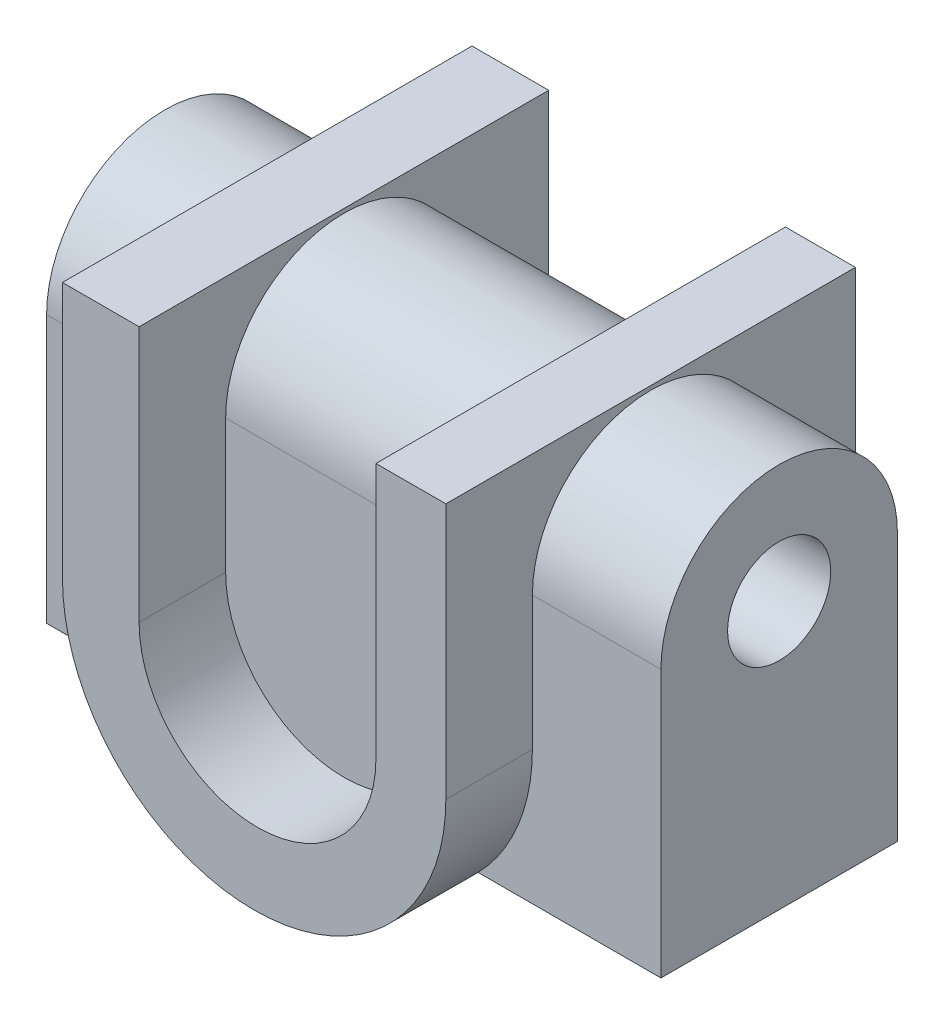
from build123d import *

# Parameters (mm, degrees)
BOSS_EXTRUDE1_DEPTH      = 40
SKETCH2_R                = 10.076891008
BOSS_EXTRUDE2_DEPTH      = 20
BOSS_EXTRUDE2_DEPTH_BACK = 100
SKETCH5_R                = 10.076891008
CUT_EXTRUDE1_DEPTH       = 101


with BuildPart() as part:
    # Sketch1 → Boss-Extrude1 (new body, symmetric)
    with BuildSketch(Plane.XY):
        with BuildLine():
            Line((0, 50.000244442), (0, 0))
            ThreePointArc((0, 0), (23.127866372, -23.127866372), (46.255732744, 0))
            Line((46.255732744, 0), (46.255732744, 50.000244442))
            Line((46.255732744, 50.000244442), (59.912187173, 50.000244442))
            Line((59.912187173, 50.000244442), (59.912187173, 0))
            ThreePointArc((59.912187173, 0), (22.46707019, -37.445116983), (-14.978046793, 0))
            Line((-14.978046793, 0), (-14.978046793, 50.000244442))
            Line((-14.978046793, 50.000244442), (0, 50.000244442))
        make_face()
    extrude(amount=BOSS_EXTRUDE1_DEPTH, both=True)

    # Sketch2 → Boss-Extrude2 (add, two sides)
    with BuildSketch(Plane.ZY.offset(14.978046793)) as boss_extrude2_sk:
        with BuildLine():
            Line((-23.095980377, -26.1078298), (23.095980377, -26.1078298))
            Line((23.095980377, -26.1078298), (23.095980377, 26.1078298))
            ThreePointArc((23.095980377, 26.1078298), (0, 49.203810178), (-23.095980377, 26.1078298))
            Line((-23.095980377, 26.1078298), (-23.095980377, -26.1078298))
        make_face()
        with Locations((0, 26.1078298)):
            Circle(SKETCH2_R, mode=Mode.SUBTRACT)
    extrude(amount=BOSS_EXTRUDE2_DEPTH)
    extrude(boss_extrude2_sk.sketch, amount=-BOSS_EXTRUDE2_DEPTH_BACK)

    # Sketch5 → Cut-Extrude1 (cut, through all)
    with BuildSketch(Plane.ZY.offset(14.978046793)):
        with Locations((0, 26.1078298)):
            Circle(SKETCH5_R)
    extrude(amount=-CUT_EXTRUDE1_DEPTH, mode=Mode.SUBTRACT)


solid = part.part
